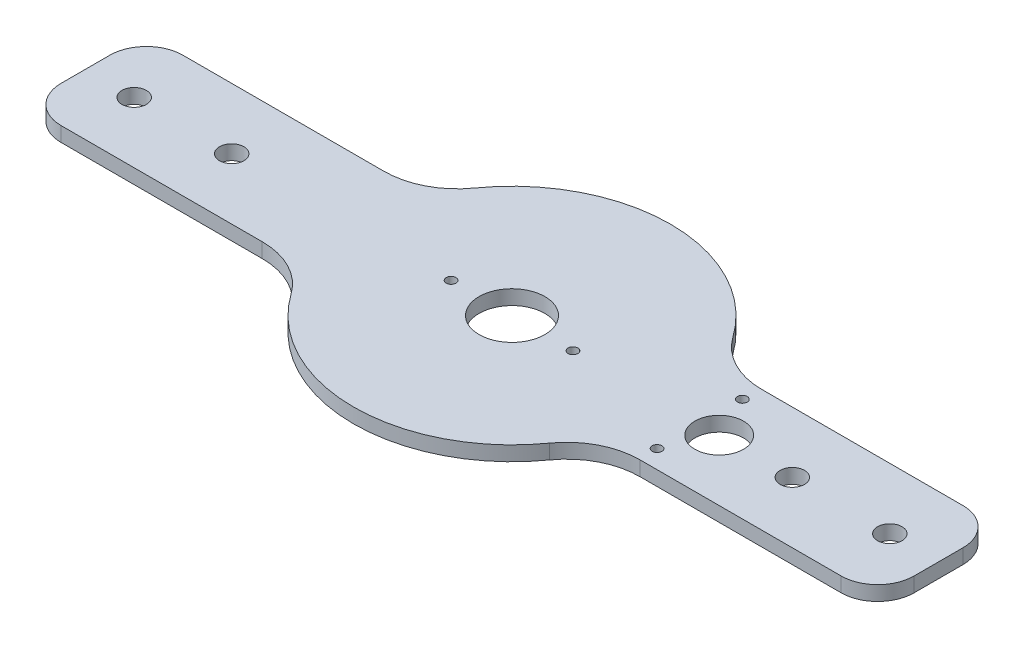
from build123d import *

# Parameters (mm, degrees)
ESQUISSE1_R        = 13.5
ESQUISSE1_R_2      = 5
ESQUISSE1_R_3      = 10
ESQUISSE1_R_4      = 2
BOSS_EXTRU_1_DEPTH = 6


with BuildPart() as part:
    # Esquisse1 → Boss.-Extru.1 (new body)
    with BuildSketch(Plane(origin=(0, 0, 0), x_dir=(1, 0, 0), z_dir=(0, 1, 0))):
        with BuildLine():
            Line((-160, 25), (-77.459666924, 25))
            ThreePointArc((-77.459666924, 25), (-63.694722892, 28.344300501), (-52.998719474, 37.631578947))
            ThreePointArc((-52.998719474, 37.631578947), (0, 65), (52.998719474, 37.631578947))
            ThreePointArc((52.998719474, 37.631578947), (63.694722892, 28.344300501), (77.459666924, 25))
            Line((77.459666924, 25), (160, 25))
            ThreePointArc((160, 25), (170.606601718, 20.606601718), (175, 10))
            Line((175, 10), (175, -10))
            ThreePointArc((175, -10), (170.606601718, -20.606601718), (160, -25))
            Line((160, -25), (77.459666924, -25))
            ThreePointArc((77.459666924, -25), (63.694722892, -28.344300501), (52.998719474, -37.631578947))
            ThreePointArc((52.998719474, -37.631578947), (0, -65), (-52.998719474, -37.631578947))
            ThreePointArc((-52.998719474, -37.631578947), (-63.694722892, -28.344300501), (-77.459666924, -25))
            Line((-77.459666924, -25), (-160, -25))
            ThreePointArc((-160, -25), (-170.606601718, -20.606601718), (-175, -10))
            Line((-175, -10), (-175, 10))
            ThreePointArc((-175, 10), (-170.606601718, 20.606601718), (-160, 25))
        make_face()
        Circle(ESQUISSE1_R, mode=Mode.SUBTRACT)
        with Locations((-115, 0)):
            Circle(ESQUISSE1_R_2, mode=Mode.SUBTRACT)
        with Locations((-155, 0)):
            Circle(ESQUISSE1_R_2, mode=Mode.SUBTRACT)
        with Locations((155, 0)):
            Circle(ESQUISSE1_R_2, mode=Mode.SUBTRACT)
        with Locations((115, 0)):
            Circle(ESQUISSE1_R_2, mode=Mode.SUBTRACT)
        with Locations((85, 0)):
            Circle(ESQUISSE1_R_3, mode=Mode.SUBTRACT)
        with Locations((-25, 0)):
            Circle(ESQUISSE1_R_4, mode=Mode.SUBTRACT)
        with Locations((25, 0)):
            Circle(ESQUISSE1_R_4, mode=Mode.SUBTRACT)
        with Locations((77, 17.5)):
            Circle(ESQUISSE1_R_4, mode=Mode.SUBTRACT)
        with Locations((77, -17.5)):
            Circle(ESQUISSE1_R_4, mode=Mode.SUBTRACT)
    extrude(amount=BOSS_EXTRU_1_DEPTH)


solid = part.part
